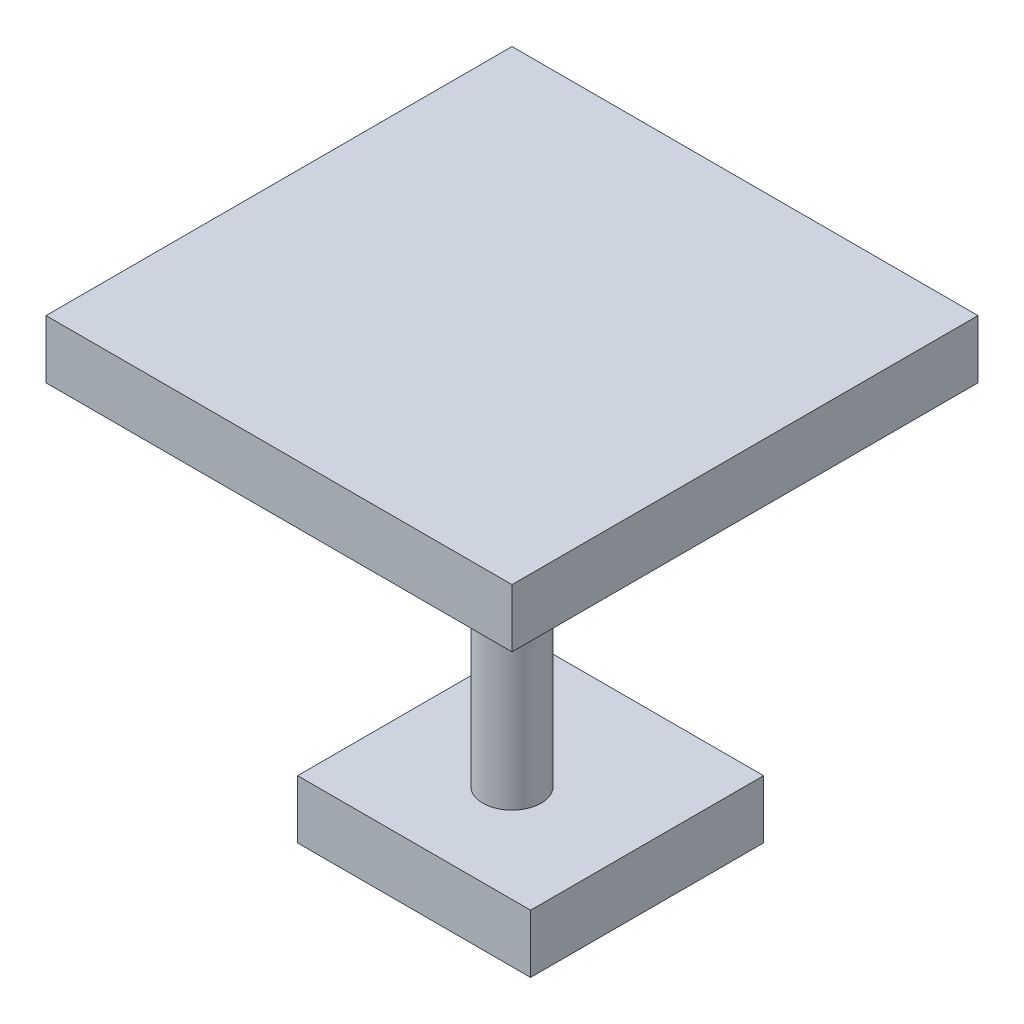
from build123d import *

# Parameters (mm, degrees)
SKETCH1_R           = 2.5
BOSS_EXTRUDE3_DEPTH = 30
SKETCH4_W           = 40
SKETCH4_H           = 40
BOSS_EXTRUDE5_DEPTH = 5
SKETCH5_W           = 20
SKETCH5_H           = 20
BOSS_EXTRUDE6_DEPTH = 5


with BuildPart() as part:
    # Sketch1 → Boss-Extrude3 (new body)
    with BuildSketch(Plane(origin=(0, 0, 0), x_dir=(1, 0, 0), z_dir=(0, 1, 0))):
        with Locations(Location((10, -10, 0), (0, 0, 270))):  # turned: the seam where the file's is
            Circle(SKETCH1_R)
    extrude(amount=BOSS_EXTRUDE3_DEPTH)

    # Sketch4 → Boss-Extrude5 (add)
    with BuildSketch(Plane(origin=(0, 30, 0), x_dir=(1, 0, 0), z_dir=(0, 1, 0))):
        with Locations((10, -10)):
            Rectangle(SKETCH4_W, SKETCH4_H)
    extrude(amount=BOSS_EXTRUDE5_DEPTH)

    # Sketch5 → Boss-Extrude6 (add)
    with BuildSketch(Plane.XZ):
        with Locations((10, 8.405143714)):
            Rectangle(SKETCH5_W, SKETCH5_H)
    extrude(amount=BOSS_EXTRUDE6_DEPTH)


solid = part.part
